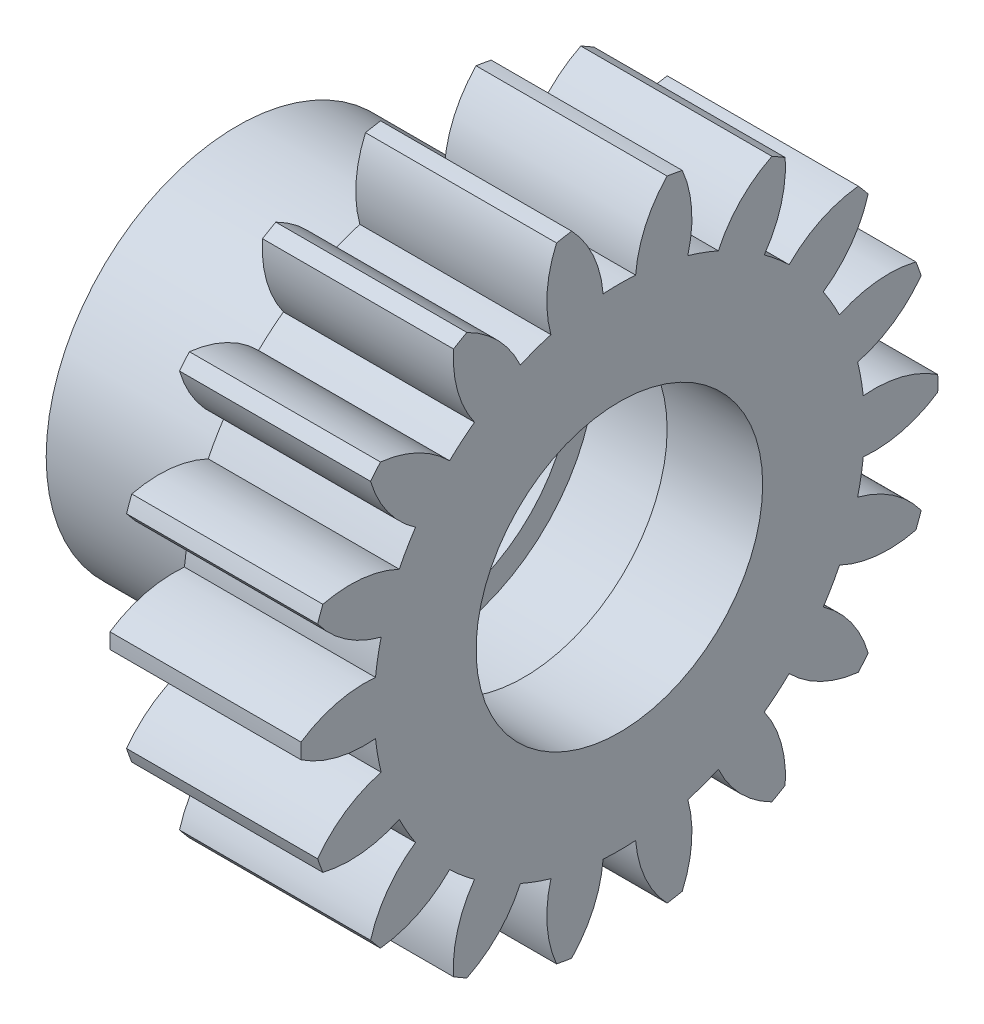
from build123d import *

# Parameters (mm, degrees)
BASPROSKE_W         = 3.175
BASPROSKE_H         = 5.291666667
TOOTHCUT_DEPTH      = 9.129212583
TEETHCUTS_COUNT     = 18
TEETHCUTS_ANGLE     = 340
BORSKE_R            = 0.396875
BORE_DEPTH          = 50.8009144
SKETCH1_R           = 2.778125
CUT_EXTRUDE2_DEPTH  = 1.5875
SKETCH3_R           = 3.175
SKETCH3_R_2         = 0.396875
BOSS_EXTRUDE1_DEPTH = 3.175
SKETCH4_R           = 2.38125
CUT_EXTRUDE3_DEPTH  = 4.7625


with BuildPart() as part:
    # BasProSke → Base-Revolve (revolve)
    with BuildSketch(Plane(origin=(0, 0, 0), x_dir=(1, 0, 0), z_dir=(0, 1, 0)), mode=Mode.PRIVATE) as base_revolve_sk:
        with Locations((1.5875, 2.645833334)):
            Rectangle(BASPROSKE_W, BASPROSKE_H)
    revolve(base_revolve_sk.sketch.rotate(Axis((-10, 0, 0), (1, 0, 0)), 180), axis=Axis((-10, 0, 0), (1, 0, 0)))

    # TooCutSke → ToothCut (cut, through all)
    with BuildSketch(Plane(origin=(0, 0, 0), x_dir=(0, 0, -1), z_dir=(1, 0, 0))):
        with BuildLine():
            ThreePointArc((0.270003318, 4.067748898), (0, 4.0767), (-0.270003318, 4.067748898))
            ThreePointArc((-0.270003318, 4.067748898), (-0.437425956, 4.709129954), (-0.814487039, 5.254313352))
            ThreePointArc((-0.814487039, 5.254313352), (0, 5.317066667), (0.814487039, 5.254313352))
            ThreePointArc((0.814487039, 5.254313352), (0.437425956, 4.709129954), (0.270003318, 4.067748898))
        make_face()
    toothcut = extrude(amount=TOOTHCUT_DEPTH, mode=Mode.SUBTRACT)

    # TeethCuts: ToothCut ×18 about axis
    teethcuts_axis = Axis((-10, 0, 0), (1, 0, 0))
    for i in range(1, TEETHCUTS_COUNT):
        add(toothcut.rotate(teethcuts_axis, i * TEETHCUTS_ANGLE / (TEETHCUTS_COUNT - 1)), mode=Mode.SUBTRACT)

    # BorSke → Bore (cut, symmetric)
    with BuildSketch(Plane(origin=(0, 0, 0), x_dir=(0, 0, -1), z_dir=(1, 0, 0))):
        with Locations(Location((0, 0, 0), (0, 0, 180))):
            Circle(BORSKE_R)
    extrude(amount=BORE_DEPTH, both=True, mode=Mode.SUBTRACT)

    # Sketch1 → Cut-Extrude2 (cut)
    with BuildSketch(Plane.ZY):
        Circle(SKETCH1_R)
    extrude(amount=-CUT_EXTRUDE2_DEPTH, mode=Mode.SUBTRACT)

    # Sketch3 → Boss-Extrude1 (add)
    with BuildSketch(Plane.ZY):
        with Locations(Location((0, 0, 0), (0, 0, 180))):
            Circle(SKETCH3_R)
        Circle(SKETCH3_R_2, mode=Mode.SUBTRACT)
    extrude(amount=BOSS_EXTRUDE1_DEPTH)

    # Sketch4 → Cut-Extrude3 (cut)
    with BuildSketch(Plane(origin=(3.175, 0, 0), x_dir=(0, 0, -1), z_dir=(1, 0, 0))):
        with Locations(Location((0, 0, 0), (0, 0, 180))):
            Circle(SKETCH4_R)
    extrude(amount=-CUT_EXTRUDE3_DEPTH, mode=Mode.SUBTRACT)


solid = part.part
